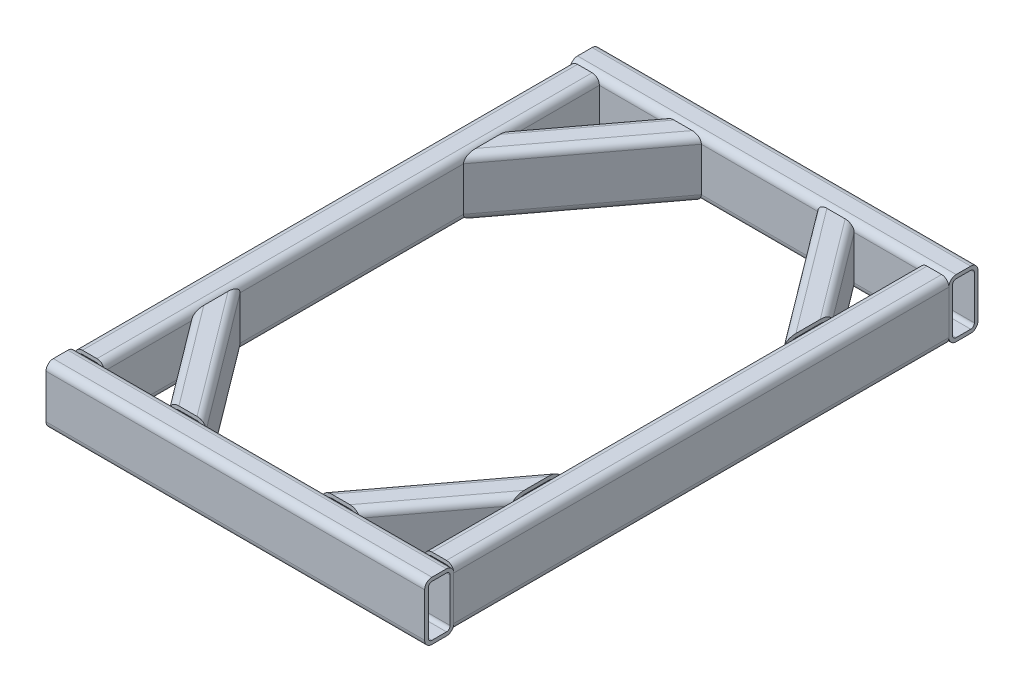
from build123d import *

# Parameters (mm, degrees)
STRUCTURAL_MEMBER1_DEPTH      = 634.999978
STRUCTURAL_MEMBER1_DEPTH_BACK = 25.399978
STRUCTURAL_MEMBER1_2_DEPTH    = 660.399956
STRUCTURAL_MEMBER1_3_DEPTH    = 916.4
STRUCTURAL_MEMBER1_4_DEPTH    = 916.4
STRUCTURAL_MEMBER1_5_DEPTH    = 437.825243312
STRUCTURAL_MEMBER1_6_DEPTH    = 437.825243312
STRUCTURAL_MEMBER1_7_DEPTH    = 437.825243312
STRUCTURAL_MEMBER1_8_DEPTH    = 437.825243312


with BuildPart() as part:
    # Sketch16 → Structural Member1 (new, two sides)
    with BuildSketch(Plane(origin=(-304.8, 0, -457.2), x_dir=(0, 0, -1), z_dir=(1, 0, 0))) as structural_member1_sk:
        with BuildLine():
            Line((-12.699978, -50.8), (12.699978, -50.8))
            ThreePointArc((12.699978, -50.8), (21.680234121, -47.080256121), (25.399978, -38.1))
            Line((25.399978, -38.1), (25.399978, 38.1))
            ThreePointArc((25.399978, 38.1), (21.680234121, 47.080256121), (12.699978, 50.8))
            Line((12.699978, 50.8), (-12.699978, 50.8))
            ThreePointArc((-12.699978, 50.8), (-21.680234121, 47.080256121), (-25.399978, 38.1))
            Line((-25.399978, 38.1), (-25.399978, -38.1))
            ThreePointArc((-25.399978, -38.1), (-21.680234121, -47.080256121), (-12.699978, -50.8))
        make_face()
        with BuildLine():
            Line((-12.699978, -44.45), (12.699978, -44.45))
            ThreePointArc((12.699978, -44.45), (17.190106061, -42.590128061), (19.049978, -38.1))
            Line((19.049978, -38.1), (19.049978, 38.1))
            ThreePointArc((19.049978, 38.1), (17.190106061, 42.590128061), (12.699978, 44.45))
            Line((12.699978, 44.45), (-12.699978, 44.45))
            ThreePointArc((-12.699978, 44.45), (-17.190106061, 42.590128061), (-19.049978, 38.1))
            Line((-19.049978, 38.1), (-19.049978, -38.1))
            ThreePointArc((-19.049978, -38.1), (-17.190106061, -42.590128061), (-12.699978, -44.45))
        make_face(mode=Mode.SUBTRACT)
    extrude(amount=STRUCTURAL_MEMBER1_DEPTH)
    extrude(structural_member1_sk.sketch, amount=-STRUCTURAL_MEMBER1_DEPTH_BACK)


with BuildPart() as body_2:
    # Sketch16 on segment 2 (carried to segment 2) → Structural Member1 2 (new body)
    with BuildSketch(Plane(origin=(-330.199978, 0, 457.2), x_dir=(0, 0, -1), z_dir=(1, 0, 0))):
        with BuildLine():
            Line((-12.699978, -50.8), (12.699978, -50.8))
            ThreePointArc((12.699978, -50.8), (21.680234121, -47.080256121), (25.399978, -38.1))
            Line((25.399978, -38.1), (25.399978, 38.1))
            ThreePointArc((25.399978, 38.1), (21.680234121, 47.080256121), (12.699978, 50.8))
            Line((12.699978, 50.8), (-12.699978, 50.8))
            ThreePointArc((-12.699978, 50.8), (-21.680234121, 47.080256121), (-25.399978, 38.1))
            Line((-25.399978, 38.1), (-25.399978, -38.1))
            ThreePointArc((-25.399978, -38.1), (-21.680234121, -47.080256121), (-12.699978, -50.8))
        make_face()
        with BuildLine():
            Line((-12.699978, -44.45), (12.699978, -44.45))
            ThreePointArc((12.699978, -44.45), (17.190106061, -42.590128061), (19.049978, -38.1))
            Line((19.049978, -38.1), (19.049978, 38.1))
            ThreePointArc((19.049978, 38.1), (17.190106061, 42.590128061), (12.699978, 44.45))
            Line((12.699978, 44.45), (-12.699978, 44.45))
            ThreePointArc((-12.699978, 44.45), (-17.190106061, 42.590128061), (-19.049978, 38.1))
            Line((-19.049978, 38.1), (-19.049978, -38.1))
            ThreePointArc((-19.049978, -38.1), (-17.190106061, -42.590128061), (-12.699978, -44.45))
        make_face(mode=Mode.SUBTRACT)
    extrude(amount=STRUCTURAL_MEMBER1_2_DEPTH)


with BuildPart() as body_3:
    # Sketch16 on segment 3 (carried to segment 3) → Structural Member1 3 (new body)
    with BuildSketch(Plane(origin=(304.8, 0, 458.2), x_dir=(-1, 0, 0), z_dir=(0, 0, -1))):
        with BuildLine():
            Line((-12.699978, -50.8), (12.699978, -50.8))
            ThreePointArc((12.699978, -50.8), (21.680234121, -47.080256121), (25.399978, -38.1))
            Line((25.399978, -38.1), (25.399978, 38.1))
            ThreePointArc((25.399978, 38.1), (21.680234121, 47.080256121), (12.699978, 50.8))
            Line((12.699978, 50.8), (-12.699978, 50.8))
            ThreePointArc((-12.699978, 50.8), (-21.680234121, 47.080256121), (-25.399978, 38.1))
            Line((-25.399978, 38.1), (-25.399978, -38.1))
            ThreePointArc((-25.399978, -38.1), (-21.680234121, -47.080256121), (-12.699978, -50.8))
        make_face()
        with BuildLine():
            Line((-12.699978, -44.45), (12.699978, -44.45))
            ThreePointArc((12.699978, -44.45), (17.190106061, -42.590128061), (19.049978, -38.1))
            Line((19.049978, -38.1), (19.049978, 38.1))
            ThreePointArc((19.049978, 38.1), (17.190106061, 42.590128061), (12.699978, 44.45))
            Line((12.699978, 44.45), (-12.699978, 44.45))
            ThreePointArc((-12.699978, 44.45), (-17.190106061, 42.590128061), (-19.049978, 38.1))
            Line((-19.049978, 38.1), (-19.049978, -38.1))
            ThreePointArc((-19.049978, -38.1), (-17.190106061, -42.590128061), (-12.699978, -44.45))
        make_face(mode=Mode.SUBTRACT)
    extrude(amount=STRUCTURAL_MEMBER1_3_DEPTH)

    # Structural Member1 3 end butt 1
    split(bisect_by=Plane(origin=(304.8, 0, 431.800022), x_dir=(0, 1, 0), z_dir=(0, 0, -1)), keep=Keep.TOP)

    # Structural Member1 3 end butt 2
    split(bisect_by=Plane(origin=(304.8, 0, -431.800022), x_dir=(0, -1, 0), z_dir=(0, 0, 1)), keep=Keep.TOP)


with BuildPart() as body_4:
    # Sketch16 on segment 4 (carried to segment 4) → Structural Member1 4 (new body)
    with BuildSketch(Plane(origin=(-304.8, 0, 458.2), x_dir=(-1, 0, 0), z_dir=(0, 0, -1))):
        with BuildLine():
            Line((-12.699978, -50.8), (12.699978, -50.8))
            ThreePointArc((12.699978, -50.8), (21.680234121, -47.080256121), (25.399978, -38.1))
            Line((25.399978, -38.1), (25.399978, 38.1))
            ThreePointArc((25.399978, 38.1), (21.680234121, 47.080256121), (12.699978, 50.8))
            Line((12.699978, 50.8), (-12.699978, 50.8))
            ThreePointArc((-12.699978, 50.8), (-21.680234121, 47.080256121), (-25.399978, 38.1))
            Line((-25.399978, 38.1), (-25.399978, -38.1))
            ThreePointArc((-25.399978, -38.1), (-21.680234121, -47.080256121), (-12.699978, -50.8))
        make_face()
        with BuildLine():
            Line((-12.699978, -44.45), (12.699978, -44.45))
            ThreePointArc((12.699978, -44.45), (17.190106061, -42.590128061), (19.049978, -38.1))
            Line((19.049978, -38.1), (19.049978, 38.1))
            ThreePointArc((19.049978, 38.1), (17.190106061, 42.590128061), (12.699978, 44.45))
            Line((12.699978, 44.45), (-12.699978, 44.45))
            ThreePointArc((-12.699978, 44.45), (-17.190106061, 42.590128061), (-19.049978, 38.1))
            Line((-19.049978, 38.1), (-19.049978, -38.1))
            ThreePointArc((-19.049978, -38.1), (-17.190106061, -42.590128061), (-12.699978, -44.45))
        make_face(mode=Mode.SUBTRACT)
    extrude(amount=STRUCTURAL_MEMBER1_4_DEPTH)

    # Structural Member1 4 end butt 1
    split(bisect_by=Plane(origin=(-304.8, 0, 431.800022), x_dir=(0, 1, 0), z_dir=(0, 0, -1)), keep=Keep.TOP)

    # Structural Member1 4 end butt 2
    split(bisect_by=Plane(origin=(-304.8, 0, -431.800022), x_dir=(0, -1, 0), z_dir=(0, 0, 1)), keep=Keep.TOP)


with BuildPart() as body_5:
    # Sketch16 on segment 5 (carried to segment 5) → Structural Member1 5 (new body)
    with BuildSketch(Plane(origin=(-350.836893432, 0, -141.817475424), x_dir=(-0.8, 0, -0.6), z_dir=(0.6, 0, -0.8))):
        with BuildLine():
            Line((-12.699978, -50.8), (12.699978, -50.8))
            ThreePointArc((12.699978, -50.8), (21.680234121, -47.080256121), (25.399978, -38.1))
            Line((25.399978, -38.1), (25.399978, 38.1))
            ThreePointArc((25.399978, 38.1), (21.680234121, 47.080256121), (12.699978, 50.8))
            Line((12.699978, 50.8), (-12.699978, 50.8))
            ThreePointArc((-12.699978, 50.8), (-21.680234121, 47.080256121), (-25.399978, 38.1))
            Line((-25.399978, 38.1), (-25.399978, -38.1))
            ThreePointArc((-25.399978, -38.1), (-21.680234121, -47.080256121), (-12.699978, -50.8))
        make_face()
        with BuildLine():
            Line((-12.699978, -44.45), (12.699978, -44.45))
            ThreePointArc((12.699978, -44.45), (17.190106061, -42.590128061), (19.049978, -38.1))
            Line((19.049978, -38.1), (19.049978, 38.1))
            ThreePointArc((19.049978, 38.1), (17.190106061, 42.590128061), (12.699978, 44.45))
            Line((12.699978, 44.45), (-12.699978, 44.45))
            ThreePointArc((-12.699978, 44.45), (-17.190106061, 42.590128061), (-19.049978, 38.1))
            Line((-19.049978, 38.1), (-19.049978, -38.1))
            ThreePointArc((-19.049978, -38.1), (-17.190106061, -42.590128061), (-12.699978, -44.45))
        make_face(mode=Mode.SUBTRACT)
    extrude(amount=STRUCTURAL_MEMBER1_5_DEPTH)

    # Structural Member1 5 end butt 1
    split(bisect_by=Plane(origin=(-279.400022, 0, -203.2), x_dir=(0, 1, 0), z_dir=(1, 0, 0)), keep=Keep.TOP)

    # Structural Member1 5 end butt 2
    split(bisect_by=Plane(origin=(-114.3, 0, -431.800022), x_dir=(0, -1, 0), z_dir=(0, 0, 1)), keep=Keep.TOP)


with BuildPart() as body_6:
    # Sketch16 on segment 6 (carried to segment 6) → Structural Member1 6 (new body)
    with BuildSketch(Plane(origin=(350.836893432, 0, -141.817475424), x_dir=(-0.8, 0, 0.6), z_dir=(-0.6, 0, -0.8))):
        with BuildLine():
            Line((-12.699978, -50.8), (12.699978, -50.8))
            ThreePointArc((12.699978, -50.8), (21.680234121, -47.080256121), (25.399978, -38.1))
            Line((25.399978, -38.1), (25.399978, 38.1))
            ThreePointArc((25.399978, 38.1), (21.680234121, 47.080256121), (12.699978, 50.8))
            Line((12.699978, 50.8), (-12.699978, 50.8))
            ThreePointArc((-12.699978, 50.8), (-21.680234121, 47.080256121), (-25.399978, 38.1))
            Line((-25.399978, 38.1), (-25.399978, -38.1))
            ThreePointArc((-25.399978, -38.1), (-21.680234121, -47.080256121), (-12.699978, -50.8))
        make_face()
        with BuildLine():
            Line((-12.699978, -44.45), (12.699978, -44.45))
            ThreePointArc((12.699978, -44.45), (17.190106061, -42.590128061), (19.049978, -38.1))
            Line((19.049978, -38.1), (19.049978, 38.1))
            ThreePointArc((19.049978, 38.1), (17.190106061, 42.590128061), (12.699978, 44.45))
            Line((12.699978, 44.45), (-12.699978, 44.45))
            ThreePointArc((-12.699978, 44.45), (-17.190106061, 42.590128061), (-19.049978, 38.1))
            Line((-19.049978, 38.1), (-19.049978, -38.1))
            ThreePointArc((-19.049978, -38.1), (-17.190106061, -42.590128061), (-12.699978, -44.45))
        make_face(mode=Mode.SUBTRACT)
    extrude(amount=STRUCTURAL_MEMBER1_6_DEPTH)

    # Structural Member1 6 end butt 1
    split(bisect_by=Plane(origin=(279.400022, 0, -203.2), x_dir=(0, -1, 0), z_dir=(-1, 0, 0)), keep=Keep.TOP)

    # Structural Member1 6 end butt 2
    split(bisect_by=Plane(origin=(114.3, 0, -431.800022), x_dir=(0, -1, 0), z_dir=(0, 0, 1)), keep=Keep.TOP)


with BuildPart() as body_7:
    # Sketch16 on segment 7 (carried to segment 7) → Structural Member1 7 (new body)
    with BuildSketch(Plane(origin=(-350.836893432, 0, 141.817475424), x_dir=(0.8, 0, -0.6), z_dir=(0.6, 0, 0.8))):
        with BuildLine():
            Line((-12.699978, -50.8), (12.699978, -50.8))
            ThreePointArc((12.699978, -50.8), (21.680234121, -47.080256121), (25.399978, -38.1))
            Line((25.399978, -38.1), (25.399978, 38.1))
            ThreePointArc((25.399978, 38.1), (21.680234121, 47.080256121), (12.699978, 50.8))
            Line((12.699978, 50.8), (-12.699978, 50.8))
            ThreePointArc((-12.699978, 50.8), (-21.680234121, 47.080256121), (-25.399978, 38.1))
            Line((-25.399978, 38.1), (-25.399978, -38.1))
            ThreePointArc((-25.399978, -38.1), (-21.680234121, -47.080256121), (-12.699978, -50.8))
        make_face()
        with BuildLine():
            Line((-12.699978, -44.45), (12.699978, -44.45))
            ThreePointArc((12.699978, -44.45), (17.190106061, -42.590128061), (19.049978, -38.1))
            Line((19.049978, -38.1), (19.049978, 38.1))
            ThreePointArc((19.049978, 38.1), (17.190106061, 42.590128061), (12.699978, 44.45))
            Line((12.699978, 44.45), (-12.699978, 44.45))
            ThreePointArc((-12.699978, 44.45), (-17.190106061, 42.590128061), (-19.049978, 38.1))
            Line((-19.049978, 38.1), (-19.049978, -38.1))
            ThreePointArc((-19.049978, -38.1), (-17.190106061, -42.590128061), (-12.699978, -44.45))
        make_face(mode=Mode.SUBTRACT)
    extrude(amount=STRUCTURAL_MEMBER1_7_DEPTH)

    # Structural Member1 7 end butt 1
    split(bisect_by=Plane(origin=(-279.400022, 0, 203.2), x_dir=(0, 1, 0), z_dir=(1, 0, 0)), keep=Keep.TOP)

    # Structural Member1 7 end butt 2
    split(bisect_by=Plane(origin=(-114.3, 0, 431.800022), x_dir=(0, 1, 0), z_dir=(0, 0, -1)), keep=Keep.TOP)


with BuildPart() as body_8:
    # Sketch16 on segment 8 (carried to segment 8) → Structural Member1 8 (new body)
    with BuildSketch(Plane(origin=(350.836893432, 0, 141.817475424), x_dir=(0.8, 0, 0.6), z_dir=(-0.6, 0, 0.8))):
        with BuildLine():
            Line((-12.699978, -50.8), (12.699978, -50.8))
            ThreePointArc((12.699978, -50.8), (21.680234121, -47.080256121), (25.399978, -38.1))
            Line((25.399978, -38.1), (25.399978, 38.1))
            ThreePointArc((25.399978, 38.1), (21.680234121, 47.080256121), (12.699978, 50.8))
            Line((12.699978, 50.8), (-12.699978, 50.8))
            ThreePointArc((-12.699978, 50.8), (-21.680234121, 47.080256121), (-25.399978, 38.1))
            Line((-25.399978, 38.1), (-25.399978, -38.1))
            ThreePointArc((-25.399978, -38.1), (-21.680234121, -47.080256121), (-12.699978, -50.8))
        make_face()
        with BuildLine():
            Line((-12.699978, -44.45), (12.699978, -44.45))
            ThreePointArc((12.699978, -44.45), (17.190106061, -42.590128061), (19.049978, -38.1))
            Line((19.049978, -38.1), (19.049978, 38.1))
            ThreePointArc((19.049978, 38.1), (17.190106061, 42.590128061), (12.699978, 44.45))
            Line((12.699978, 44.45), (-12.699978, 44.45))
            ThreePointArc((-12.699978, 44.45), (-17.190106061, 42.590128061), (-19.049978, 38.1))
            Line((-19.049978, 38.1), (-19.049978, -38.1))
            ThreePointArc((-19.049978, -38.1), (-17.190106061, -42.590128061), (-12.699978, -44.45))
        make_face(mode=Mode.SUBTRACT)
    extrude(amount=STRUCTURAL_MEMBER1_8_DEPTH)

    # Structural Member1 8 end butt 1
    split(bisect_by=Plane(origin=(279.400022, 0, 203.2), x_dir=(0, -1, 0), z_dir=(-1, 0, 0)), keep=Keep.TOP)

    # Structural Member1 8 end butt 2
    split(bisect_by=Plane(origin=(114.3, 0, 431.800022), x_dir=(0, 1, 0), z_dir=(0, 0, -1)), keep=Keep.TOP)


solid = Compound([part.part, body_2.part, body_3.part, body_4.part, body_5.part, body_6.part, body_7.part, body_8.part])
